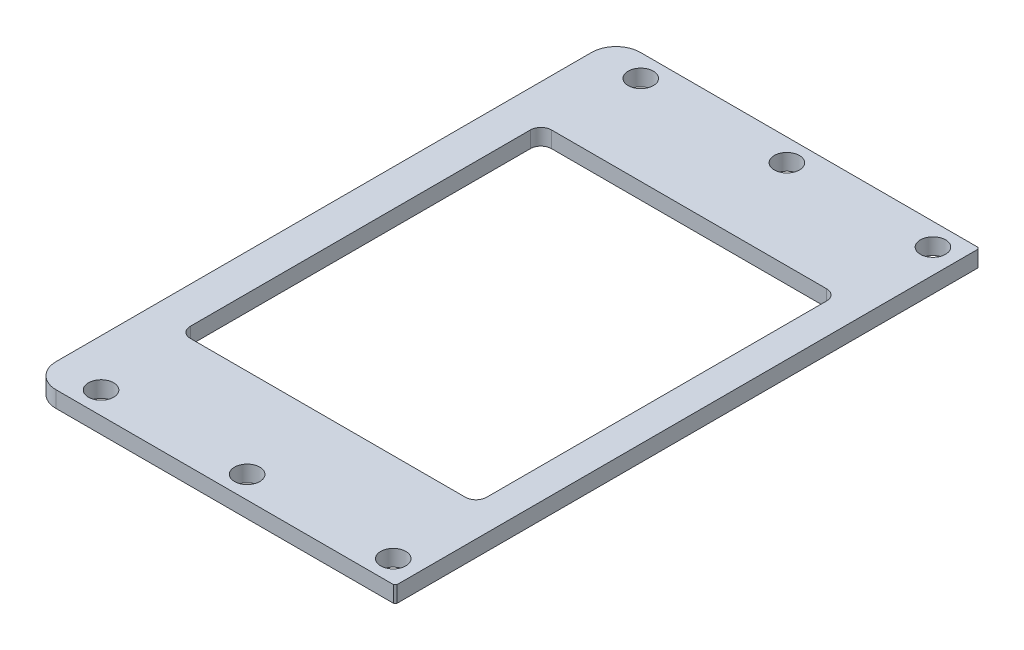
from build123d import *

# Parameters (mm, degrees)
SKETCH1_W           = 44.8
SKETCH1_H           = 72
SKETCH1_R           = 1.55
BOSS_EXTRUDE1_DEPTH = 2
CHAMFER2_SIZE       = 0.2
FILLET3_R           = 3


with BuildPart() as part:
    # Sketch1 → Boss-Extrude1 (new body)
    with BuildSketch(Plane(origin=(0, 0, 0), x_dir=(1, 0, 0), z_dir=(0, 1, 0))):
        Rectangle(SKETCH1_W, SKETCH1_H)
        with Locations((-16.6, -33.25)):
            Circle(SKETCH1_R, mode=Mode.SUBTRACT)
        with Locations((1.4, -33.25)):
            Circle(SKETCH1_R, mode=Mode.SUBTRACT)
        with Locations((19.4, -33.25)):
            Circle(SKETCH1_R, mode=Mode.SUBTRACT)
        with Locations((-16.6, 33.25)):
            Circle(SKETCH1_R, mode=Mode.SUBTRACT)
        with Locations((1.4, 33.25)):
            Circle(SKETCH1_R, mode=Mode.SUBTRACT)
        with Locations((19.4, 33.25)):
            Circle(SKETCH1_R, mode=Mode.SUBTRACT)
        with BuildLine():
            Line((17.3, -22.25), (-16.6, -22.25))
            ThreePointArc((-16.6, -22.25), (-17.519238816, -21.869238816), (-17.9, -20.95))
            Line((-17.9, -20.95), (-17.9, 20.95))
            ThreePointArc((-17.9, 20.95), (-17.519238816, 21.869238816), (-16.6, 22.25))
            Line((-16.6, 22.25), (17.3, 22.25))
            ThreePointArc((17.3, 22.25), (18.219238816, 21.869238816), (18.6, 20.95))
            Line((18.6, 20.95), (18.6, -20.95))
            ThreePointArc((18.6, -20.95), (18.219238816, -21.869238816), (17.3, -22.25))
        make_face(mode=Mode.SUBTRACT)
    extrude(amount=BOSS_EXTRUDE1_DEPTH)

    # Chamfer2
    chamfer2_edges = [part.edges().sort_by_distance(p)[0] for p in [
        (22.4, 1, -36),
        (22.4, 1, 36),
    ]]
    chamfer(chamfer2_edges, length=CHAMFER2_SIZE)

    # Fillet3
    fillet3_edges = [part.edges().sort_by_distance(p)[0] for p in [
        (-22.4, 1, 36),
        (-22.4, 1, -36),
    ]]
    fillet(fillet3_edges, radius=FILLET3_R)


solid = part.part
